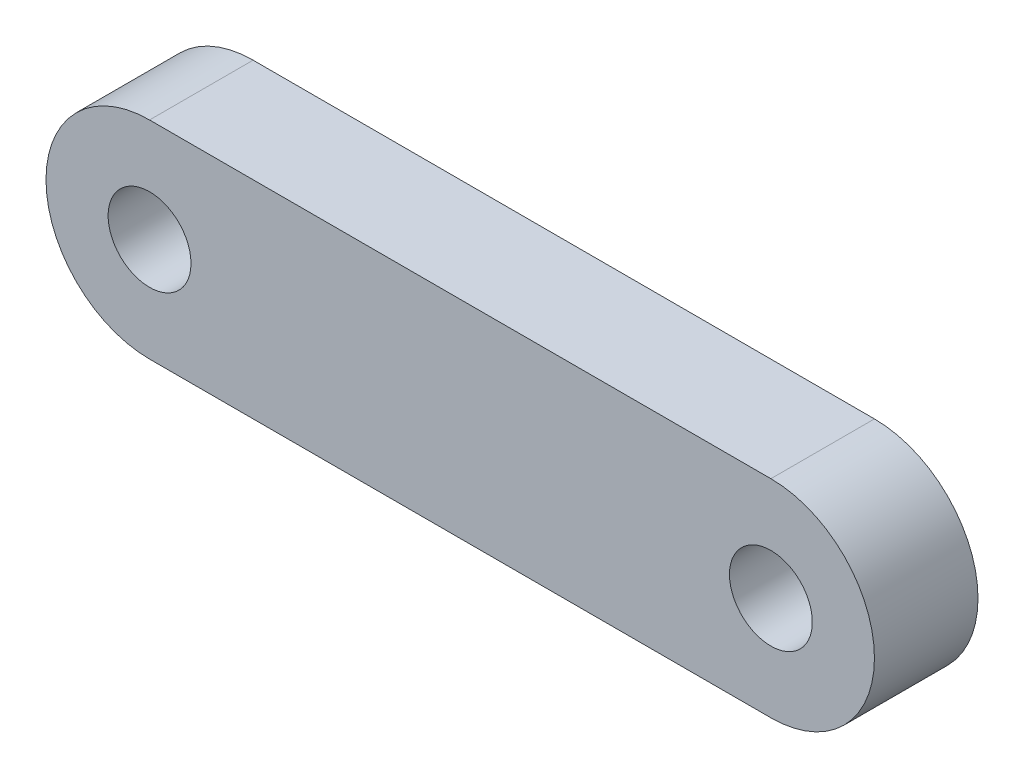
from build123d import *

# Parameters (mm, degrees)
SKETCH_1_R      = 2
EXTRUDE_1_DEPTH = 5


with BuildPart() as part:
    # 草图1 → 凸台-拉伸1 (new body)
    with BuildSketch(Plane.XY):
        with BuildLine():
            Line((-15, 5), (15, 5))
            ThreePointArc((15, 5), (20, 0), (15, -5))
            Line((15, -5), (-15, -5))
            ThreePointArc((-15, -5), (-20, 0), (-15, 5))
        make_face()
        with Locations((-15, 0)):
            Circle(SKETCH_1_R, mode=Mode.SUBTRACT)
        with Locations((15, 0)):
            Circle(SKETCH_1_R, mode=Mode.SUBTRACT)
    extrude(amount=EXTRUDE_1_DEPTH)


solid = part.part
